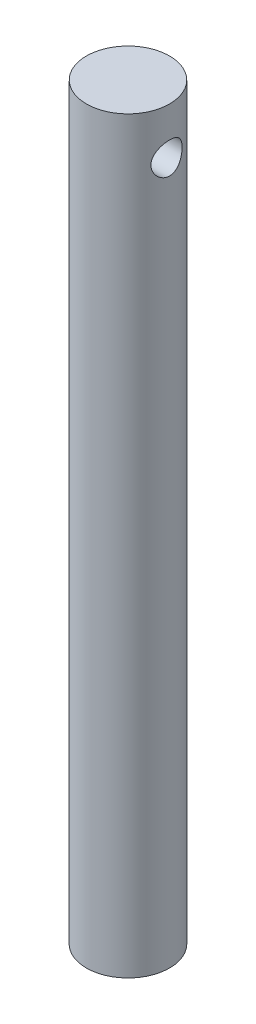
from build123d import *

# Parameters (mm, degrees)
SKETCH1_R           = 2
BOSS_EXTRUDE1_DEPTH = 36
SKETCH2_R           = 0.75
CUT_EXTRUDE1_DEPTH  = 18


with BuildPart() as part:
    # Sketch1 → Boss-Extrude1 (new body)
    with BuildSketch(Plane(origin=(0, 0, 0), x_dir=(1, 0, 0), z_dir=(0, 1, 0))):
        Circle(SKETCH1_R)
    extrude(amount=BOSS_EXTRUDE1_DEPTH)

    # Sketch2 → Cut-Extrude1 (cut, symmetric)
    with BuildSketch(Plane(origin=(0, 0, 0), x_dir=(0, 0, -1), z_dir=(1, 0, 0))):
        with Locations((0, 33.75)):
            Circle(SKETCH2_R)
    extrude(amount=CUT_EXTRUDE1_DEPTH, both=True, mode=Mode.SUBTRACT)


solid = part.part
